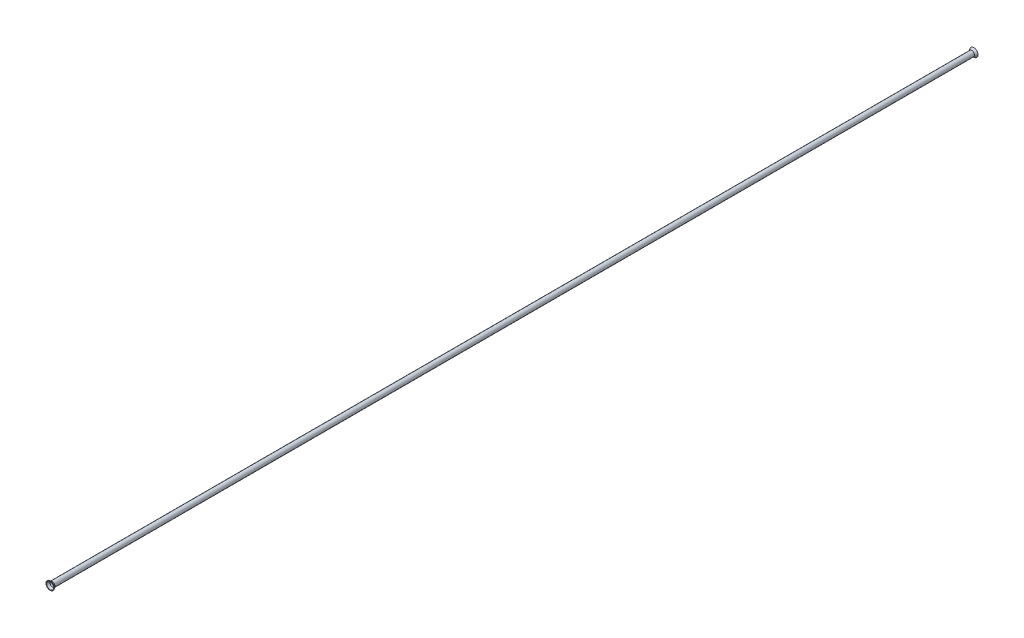
from build123d import *

# Parameters (mm, degrees)
SKETCH1_R           = 2.38125
SKETCH1_R_2         = 1.82245
BOSS_EXTRUDE1_DEPTH = 408.7876
SKETCH2_R           = 2.38125
BOSS_EXTRUDE2_DEPTH = 1.778
BOSS_EXTRUDE2_TAPER = -37
SKETCH3_R           = 1.82245
CUT_EXTRUDE1_DEPTH  = 2.7780001
CUT_EXTRUDE1_TAPER  = -37


with BuildPart() as part:
    # Sketch1 → Boss-Extrude1 (new body, symmetric)
    with BuildSketch(Plane.XY):
        Circle(SKETCH1_R)
        Circle(SKETCH1_R_2, mode=Mode.SUBTRACT)
    extrude(amount=BOSS_EXTRUDE1_DEPTH, both=True)

    # Sketch2 → Boss-Extrude2 (add)
    with BuildSketch(Plane.XY.offset(408.7876)):
        Circle(SKETCH2_R)
    boss_extrude2 = extrude(amount=BOSS_EXTRUDE2_DEPTH, taper=BOSS_EXTRUDE2_TAPER)

    # Sketch3 → Cut-Extrude1 (cut, through all)
    with BuildSketch(Plane(origin=(0, 0, 408.7876), x_dir=(-1, 0, 0), z_dir=(0, 0, -1))):
        Circle(SKETCH3_R)
    cut_extrude1 = extrude(amount=-CUT_EXTRUDE1_DEPTH, taper=CUT_EXTRUDE1_TAPER, mode=Mode.SUBTRACT)

    # Mirror1: Boss-Extrude2, Cut-Extrude1 across plane
    add(boss_extrude2.mirror(Plane.XY))
    add(cut_extrude1.mirror(Plane.XY), mode=Mode.SUBTRACT)


solid = part.part
